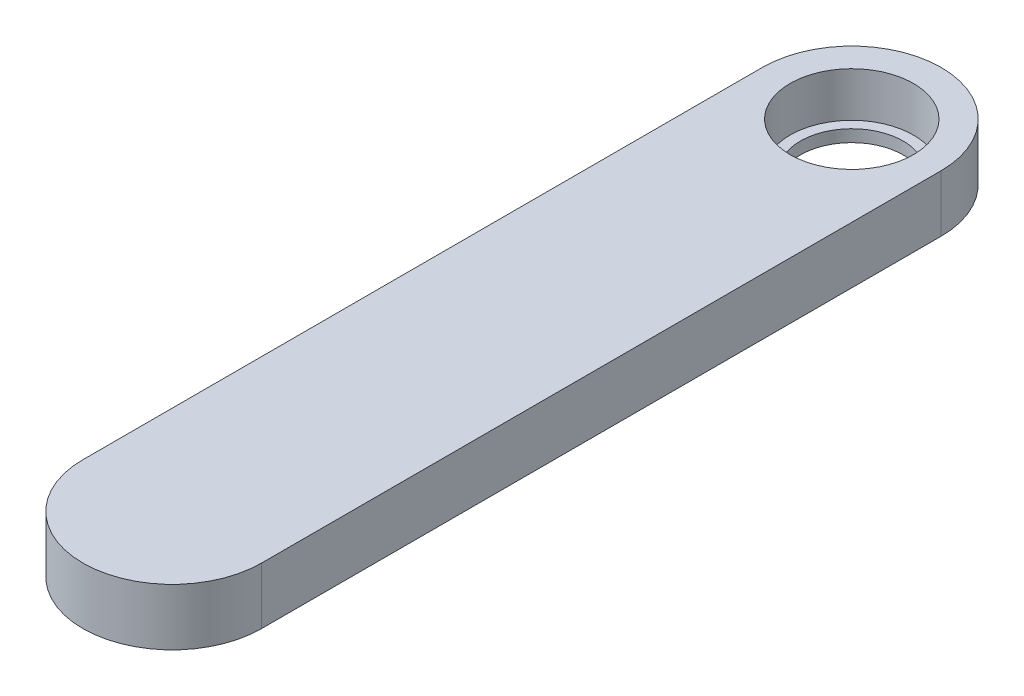
from build123d import *

# Parameters (mm, degrees)
SKETCH1_W           = 10
SKETCH1_H           = 38
BOSS_EXTRUDE1_DEPTH = 1.5875
SKETCH2_R           = 3.45
CUT_EXTRUDE1_DEPTH  = 2.5
SKETCH3_R           = 2.875
CUT_EXTRUDE2_DEPTH  = 1.675


with BuildPart() as part:
    # Sketch1 → Boss-Extrude1 (new body, symmetric)
    with BuildSketch(Plane(origin=(0, 0, 0), x_dir=(1, 0, 0), z_dir=(0, 1, 0))):
        with BuildLine():
            ThreePointArc((-5, 19), (0, 24), (5, 19))
            Line((5, 19), (-5, 19))
        make_face()
        Rectangle(SKETCH1_W, SKETCH1_H)
        with BuildLine():
            Line((5, -19), (-5, -19))
            ThreePointArc((-5, -19), (0, -24), (5, -19))
        make_face()
    extrude(amount=BOSS_EXTRUDE1_DEPTH, both=True)

    # Sketch2 → Cut-Extrude1 (cut)
    with BuildSketch(Plane(origin=(0, 1.5875, 0), x_dir=(1, 0, 0), z_dir=(0, 1, 0))):
        with Locations((0, 19)):
            Circle(SKETCH2_R)
    extrude(amount=-CUT_EXTRUDE1_DEPTH, mode=Mode.SUBTRACT)

    # Sketch3 → Cut-Extrude2 (cut, through all)
    with BuildSketch(Plane(origin=(0, -0.9125, 0), x_dir=(1, 0, 0), z_dir=(0, 1, 0))):
        with Locations((0, 19)):
            Circle(SKETCH3_R)
    extrude(amount=-CUT_EXTRUDE2_DEPTH, mode=Mode.SUBTRACT)


solid = part.part
